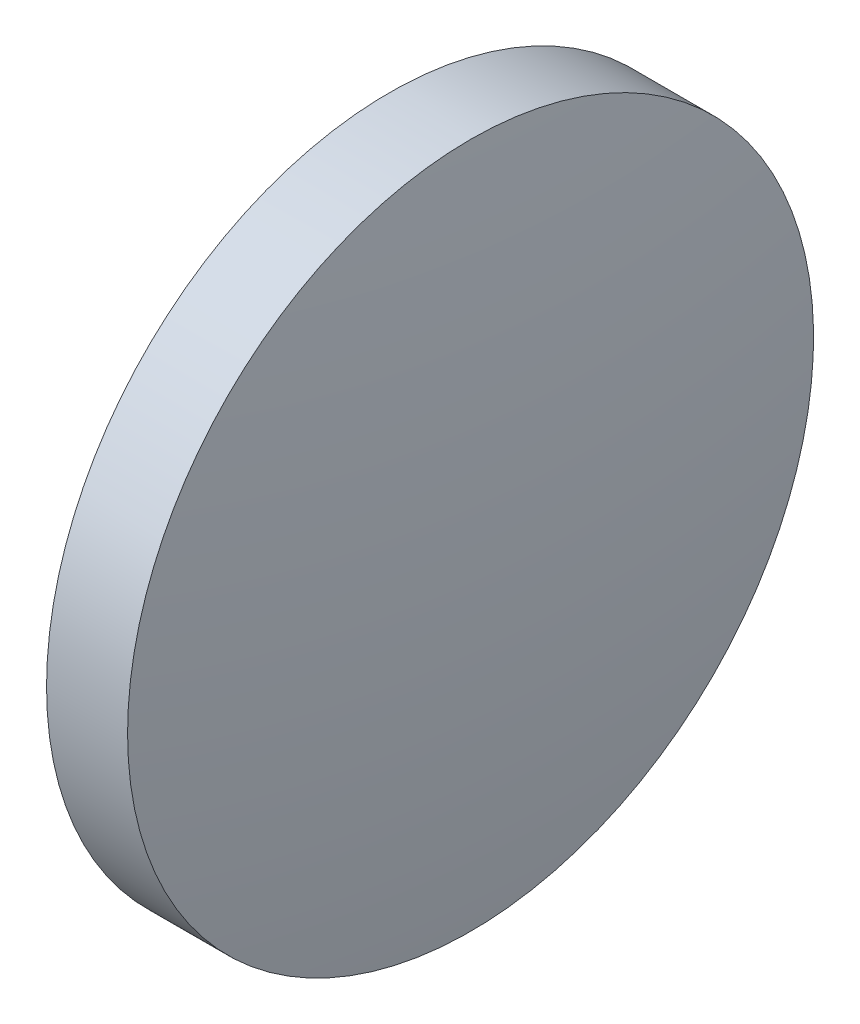
from build123d import *


with BuildPart() as part:
    # 草图1 → 旋转1 (revolve)
    with BuildSketch(Plane.XY):
        with BuildLine():
            Line((115.773606431, 65.233554926), (115.773606431, 77.933554926))
            Line((115.773606431, 77.933554926), (118.773876517, 77.933554926))
            ThreePointArc((118.773876517, 77.933554926), (119.435658058, 71.598875266), (119.656606431, 65.233554926))
            Line((119.656606431, 65.233554926), (115.773606431, 65.233554926))
        make_face()
    revolve(axis=Axis((110.165373228, 65.233554926, 0), (1, 0, 0)))


solid = part.part
